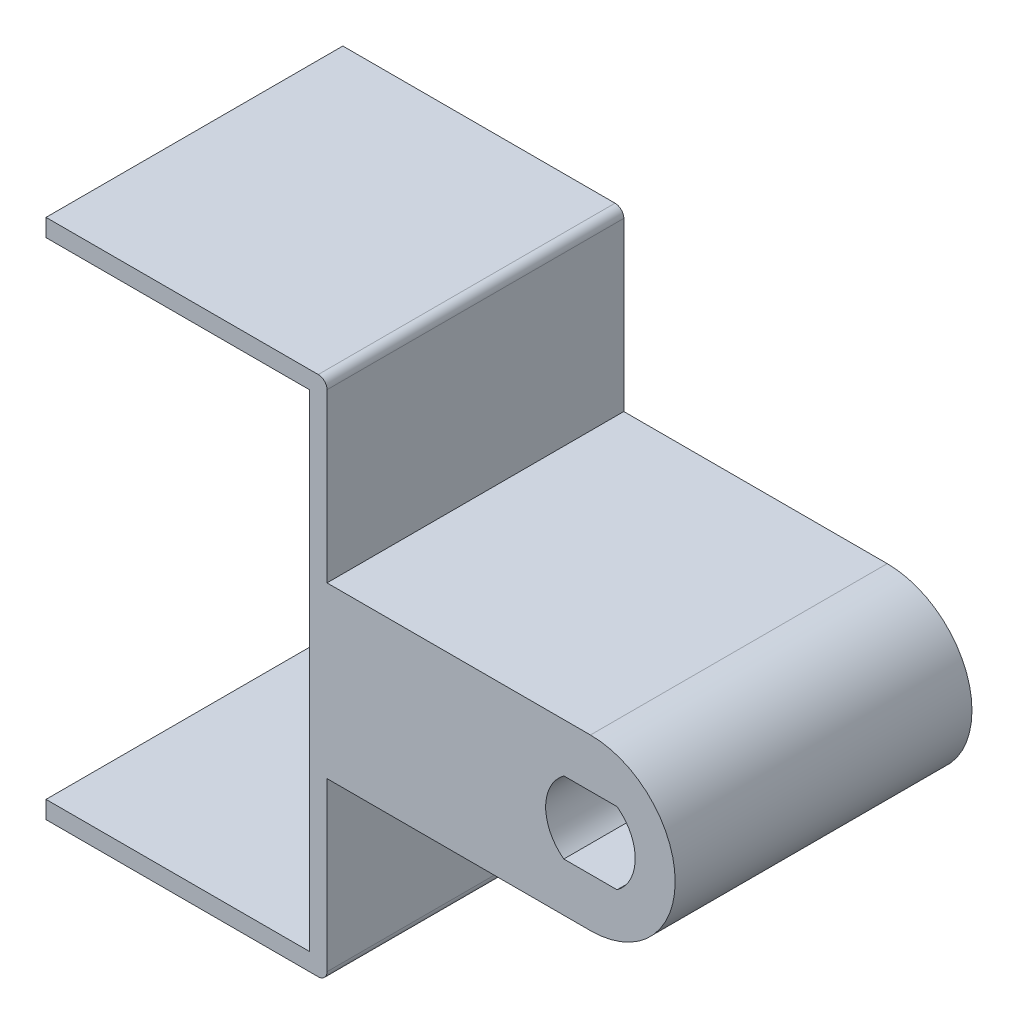
from build123d import *
from OCP.BRepFilletAPI import BRepFilletAPI_MakeChamfer

# Parameters (mm, degrees)
BOSS_EXTRUDE1_DEPTH = 16.9
BOSS_EXTRUDE2_DEPTH = 13.5
BOSS_EXTRUDE3_DEPTH = 3.4
BOSS_EXTRUDE4_DEPTH = 13.5
CUT_EXTRUDE1_DEPTH  = 46.491242289
CHAMFER1_SIZE       = 2
CHAMFER1_SIZE2      = 1.154700538
CUT_EXTRUDE2_DEPTH  = 47.613443608
FILLET1_R           = 0.5
SKETCH10_W          = 25
SKETCH10_H          = 29.7
CUT_EXTRUDE3_DEPTH  = 47.613443644


with BuildPart() as part:
    # Sketch1 → Boss-Extrude1 (new body)
    with BuildSketch(Plane.XY):
        Polygon((-20, -13.85), (20, -13.85), (20, 13.85), (-20, 13.85), (-20, 14.85), (21, 14.85), (21, -14.85), (-20, -14.85), align=None)
    extrude(amount=BOSS_EXTRUDE1_DEPTH)

    # Sketch4 → Boss-Extrude2 (add)
    with BuildSketch(Plane(origin=(0, 0, 0), x_dir=(-1, 0, 0), z_dir=(0, 0, -1))):
        with BuildLine():
            Line((-21, 4.825), (-36, 4.825))
            ThreePointArc((-36, 4.825), (-38.610615349, 4.05774722), (-40.390970849, 2))
            Line((-40.390970849, 2), (-30.875, 2))
            Line((-30.875, 2), (-30.875, -2))
            Line((-30.875, -2), (-40.390970849, -2))
            ThreePointArc((-40.390970849, -2), (-38.610615349, -4.05774722), (-36, -4.825))
            Line((-36, -4.825), (-21, -4.825))
            Line((-21, -4.825), (-21, 4.825))
        make_face()
    extrude(amount=-BOSS_EXTRUDE2_DEPTH)

    # Sketch5 → Boss-Extrude3 (add)
    with BuildSketch(Plane.XY.offset(13.5)):
        with BuildLine():
            Line((21, 4.825), (21, -4.825))
            Line((21, -4.825), (36, -4.825))
            ThreePointArc((36, -4.825), (38.610615349, -4.05774722), (40.390970849, -2))
            ThreePointArc((40.390970849, -2), (40.825, 0), (40.390970849, 2))
            ThreePointArc((40.390970849, 2), (38.610615349, 4.05774722), (36, 4.825))
            Line((36, 4.825), (21, 4.825))
        make_face()
    extrude(amount=BOSS_EXTRUDE3_DEPTH)

    # Sketch8 → Boss-Extrude4 (add)
    with BuildSketch(Plane(origin=(0, 0, 0), x_dir=(-1, 0, 0), z_dir=(0, 0, -1))):
        with BuildLine():
            Line((-37.5, 2), (-40.390970849, 2))
            ThreePointArc((-40.390970849, 2), (-40.825, 0), (-40.390970849, -2))
            Line((-40.390970849, -2), (-37.5, -2))
            ThreePointArc((-37.5, -2), (-38.5, 0), (-37.5, 2))
        make_face()
        with BuildLine():
            Line((-34.5, 2), (-30.875, 2))
            Line((-30.875, 2), (-30.875, -2))
            Line((-30.875, -2), (-34.5, -2))
            ThreePointArc((-34.5, -2), (-33.5, 0), (-34.5, 2))
        make_face()
    extrude(amount=-BOSS_EXTRUDE4_DEPTH)

    # Sketch9 → Cut-Extrude1 (cut, through all)
    with BuildSketch(Plane(origin=(0, 0, 13.5), x_dir=(-1, 0, 0), z_dir=(0, 0, -1))):
        with BuildLine():
            Line((-37.5, -2), (-34.5, -2))
            ThreePointArc((-34.5, -2), (-33.5, 0), (-34.5, 2))
            Line((-34.5, 2), (-37.5, 2))
            ThreePointArc((-37.5, 2), (-38.5, 0), (-37.5, -2))
        make_face()
    extrude(amount=-CUT_EXTRUDE1_DEPTH, mode=Mode.SUBTRACT)

    # Chamfer1: one chamfer whose edges measure the first distance from different faces: ONE call of the kernel's chamfer builder (chamfer() names one face for all edges)
    chamfer1_edges_1 = [part.edges().sort_by_distance(p)[0] for p in [
        (36, 2, 0),
    ]]
    chamfer1_side_1 = [part.faces().sort_by_distance(p)[0] for p in [
        (36, 2, 8.45),
    ]]
    chamfer1_edges_2 = [part.edges().sort_by_distance(p)[0] for p in [
        (38.5, 0, 0),
    ]]
    chamfer1_side_2 = [part.faces().sort_by_distance(p)[0] for p in [
        (38.5, 0, 8.45),
    ]]
    chamfer1_edges_3 = [part.edges().sort_by_distance(p)[0] for p in [
        (36, -2, 0),
    ]]
    chamfer1_side_3 = [part.faces().sort_by_distance(p)[0] for p in [
        (36, -2, 8.45),
    ]]
    chamfer1_edges_4 = [part.edges().sort_by_distance(p)[0] for p in [
        (33.5, 0, 0),
    ]]
    chamfer1_side_4 = [part.faces().sort_by_distance(p)[0] for p in [
        (33.5, 0, 8.45),
    ]]
    chamfer1 = BRepFilletAPI_MakeChamfer(part.part.solid().wrapped)
    for e in chamfer1_edges_1:
        chamfer1.Add(CHAMFER1_SIZE, CHAMFER1_SIZE2, e.wrapped, chamfer1_side_1[0].wrapped)  # the first distance lies on this face
    for e in chamfer1_edges_2:
        chamfer1.Add(CHAMFER1_SIZE, CHAMFER1_SIZE2, e.wrapped, chamfer1_side_2[0].wrapped)  # the first distance lies on this face
    for e in chamfer1_edges_3:
        chamfer1.Add(CHAMFER1_SIZE, CHAMFER1_SIZE2, e.wrapped, chamfer1_side_3[0].wrapped)  # the first distance lies on this face
    for e in chamfer1_edges_4:
        chamfer1.Add(CHAMFER1_SIZE, CHAMFER1_SIZE2, e.wrapped, chamfer1_side_4[0].wrapped)  # the first distance lies on this face
    add(Compound.cast(chamfer1.Shape()), mode=Mode.REPLACE)

    # Sketch11 → Cut-Extrude2 (cut, through all)
    with BuildSketch(Plane(origin=(0, 0, 0), x_dir=(-1, 0, 0), z_dir=(0, 0, -1))):
        with BuildLine():
            Line((-34.483424911, 2.05), (-37.516575089, 2.05))
            ThreePointArc((-37.516575089, 2.05), (-38.55, 0), (-37.516575089, -2.05))
            Line((-37.516575089, -2.05), (-34.483424911, -2.05))
            ThreePointArc((-34.483424911, -2.05), (-33.45, 0), (-34.483424911, 2.05))
        make_face()
    extrude(amount=-CUT_EXTRUDE2_DEPTH, mode=Mode.SUBTRACT)

    # Fillet1
    fillet1_edges = [part.edges().sort_by_distance(p)[0] for p in [
        (-20, 14.85, 8.45),
        (21, 14.85, 8.45),
        (21, -14.85, 8.45),
        (-20, -14.85, 8.45),
    ]]
    fillet(fillet1_edges, radius=FILLET1_R)

    # Sketch10 → Cut-Extrude3 (cut, through all)
    with BuildSketch(Plane(origin=(0, 0, 0), x_dir=(-1, 0, 0), z_dir=(0, 0, -1))):
        with Locations((7.5, 0)):
            Rectangle(SKETCH10_W, SKETCH10_H)
    extrude(amount=-CUT_EXTRUDE3_DEPTH, mode=Mode.SUBTRACT)


solid = part.part
